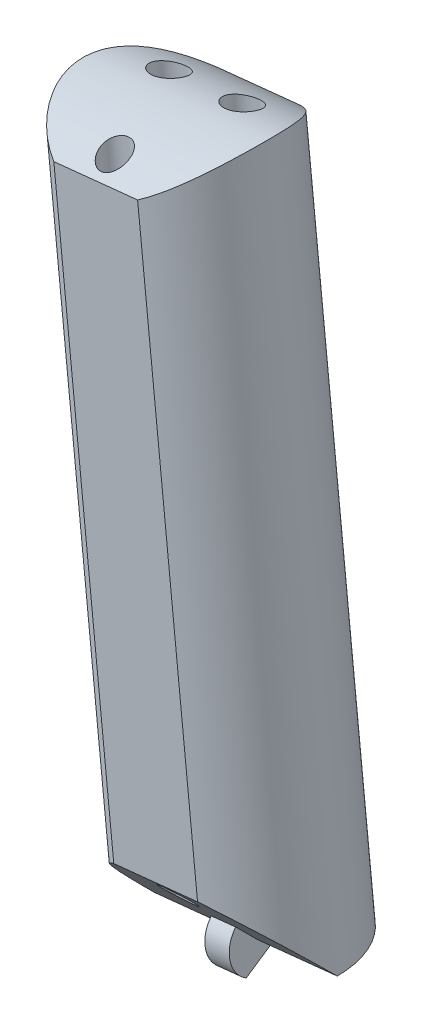
from build123d import *

# Parameters (mm, degrees)
SKETCH3_R               = 9
BOSS_EXTRUDE1_DEPTH     = 69
CUT_EXTRUDE1_DEPTH      = 220.929043992
CUT_EXTRUDE1_DEPTH_BACK = 220.929043992
CUT_EXTRUDE2_DEPTH      = 219.597133119
CUT_EXTRUDE2_DEPTH_BACK = 219.597133119
BOSS_EXTRUDE3_DEPTH     = 1.2
SKETCH8_R               = 1.6
SKETCH8_R_2             = 1.4
CUT_EXTRUDE3_DEPTH      = 74.512311312
CUT_EXTRUDE3_DEPTH_BACK = 74.512311312
CUT_EXTRUDE4_DEPTH      = 73.514420315


with BuildPart() as part:
    # Sketch3 → Boss-Extrude1 (new body)
    with BuildSketch(Plane(origin=(-12.082314344, 217.636022384, 0), x_dir=(-0.9946657577296572, -0.10315052302381673, 0), z_dir=(0.10315052302381673, -0.9946657577296572, 0))):
        with Locations(Location((0, 0, 0), (0, 0, 180))):
            Circle(SKETCH3_R)
    extrude(amount=BOSS_EXTRUDE1_DEPTH)

    # Sketch4 → Cut-Extrude1 (cut, two sides)
    with BuildSketch(Plane(origin=(10.375761543, 1.076004901, 0), x_dir=(0.10315052302381672, -0.9946657577296572, 0), z_dir=(-0.9946657577296572, -0.10315052302381673, 0))) as cut_extrude1_sk:
        with BuildLine():
            Line((-217.721396158, 9), (-212.721396158, 9))
            ThreePointArc((-212.721396158, 9), (-216.387282909, 0), (-212.721396158, -9))
            Line((-212.721396158, -9), (-217.721396158, -9))
            Line((-217.721396158, -9), (-217.721396158, 9))
        make_face()
    extrude(amount=CUT_EXTRUDE1_DEPTH, mode=Mode.SUBTRACT)
    extrude(cut_extrude1_sk.sketch, amount=-CUT_EXTRUDE1_DEPTH_BACK, mode=Mode.SUBTRACT)

    # Sketch5 → Cut-Extrude2 (cut, two sides)
    with BuildSketch(Plane(origin=(10.375761543, 1.076004901, 0), x_dir=(0.10315052302381672, -0.9946657577296572, 0), z_dir=(-0.9946657577296572, -0.10315052302381673, 0))) as cut_extrude2_sk:
        Polygon((-148.721396158, 0), (-157.721396158, 9), (-148.721396158, 9), align=None)
    extrude(amount=CUT_EXTRUDE2_DEPTH, mode=Mode.SUBTRACT)
    extrude(cut_extrude2_sk.sketch, amount=-CUT_EXTRUDE2_DEPTH_BACK, mode=Mode.SUBTRACT)

    # Sketch7 → Boss-Extrude3 (add, symmetric)
    with BuildSketch(Plane(origin=(10.375761543, 1.076004901, 0), x_dir=(0.10315052302381672, -0.9946657577296572, 0), z_dir=(-0.9946657577296572, -0.10315052302381673, 0))):
        with BuildLine():
            Line((-151.519146847, 0.112209978), (-148.721396158, 0))
            Line((-148.721396158, 0), (-148.721396158, -2.8))
            Line((-148.721396158, -2.8), (-146.296525027, 1.4))
            ThreePointArc((-146.296525027, 1.4), (-149.391739784, 2.718573049), (-151.519146847, 0.112209978))
        make_face()
    extrude(amount=BOSS_EXTRUDE3_DEPTH, both=True)

    # Sketch8 → Cut-Extrude3 (cut, two sides)
    with BuildSketch(Plane(origin=(-12.082314344, 217.636022384, 0), x_dir=(-0.9946657577296572, -0.10315052302381673, 0), z_dir=(0.10315052302381673, -0.9946657577296572, 0))) as cut_extrude3_sk:
        with Locations(Location((-3.6, 3, 0), (0, 0, 180))):
            Circle(SKETCH8_R)
        with Locations(Location((3.6, 3, 0), (0, 0, 180))):
            Circle(SKETCH8_R)
        with Locations(Location((0, -6, 0), (0, 0, 180))):
            Circle(SKETCH8_R_2)
    extrude(amount=CUT_EXTRUDE3_DEPTH, mode=Mode.SUBTRACT)
    extrude(cut_extrude3_sk.sketch, amount=-CUT_EXTRUDE3_DEPTH_BACK, mode=Mode.SUBTRACT)

    # Sketch9 → Cut-Extrude4 (cut, through all)
    with BuildSketch(Plane(origin=(-15.340689799, 147.9280802, 0), x_dir=(0.9946657577296572, 0.10315052302381673, 0), z_dir=(0.10315052302381673, -0.9946657577296572, 0))):
        with BuildLine():
            Line((6.30829956, -8), (14.554510811, -8))
            ThreePointArc((14.554510811, -8), (10.431405186, -9), (6.30829956, -8))
        make_face()
        with BuildLine():
            Line((6.30829956, 8), (14.554510811, 8))
            ThreePointArc((14.554510811, 8), (10.431405186, 9), (6.30829956, 8))
        make_face()
    extrude(amount=-CUT_EXTRUDE4_DEPTH, mode=Mode.SUBTRACT)


solid = part.part
